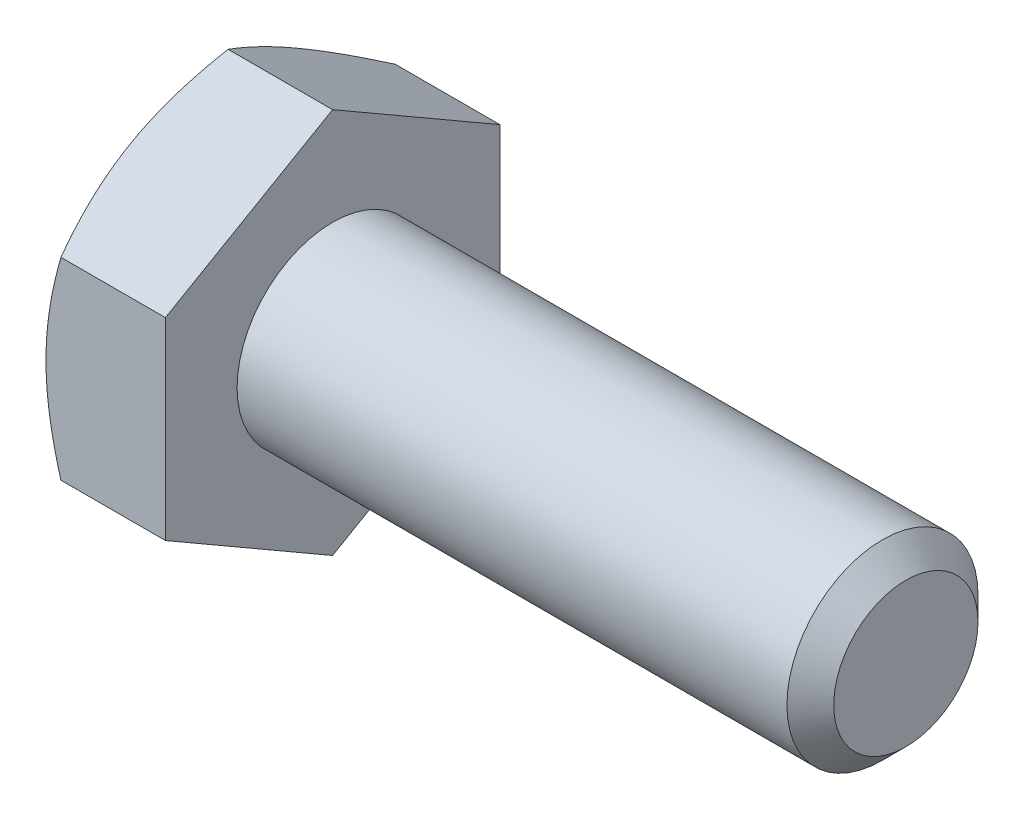
from build123d import *

# Parameters (mm, degrees)
SKETCH5_R           = 3.175
BOSS_EXTRUDE3_DEPTH = 19.05
CHAMFER1_SIZE       = 0.77724
BOSS_EXTRUDE4_DEPTH = 3.96875
SKETCH8_OUTSIDE_W   = 102.036
SKETCH8_OUTSIDE_H   = 103.756
SKETCH8_OUTSIDE_R   = 5.55625
CUT_EXTRUDE3_DEPTH  = 24.01875
CUT_EXTRUDE3_TAPER  = 60
CUT_EXTRUDE4_DEPTH  = 0.254
CIRPATTERN1_COUNT   = 3


with BuildPart() as part:
    # Sketch5 → Boss-Extrude3 (new body)
    with BuildSketch(Plane(origin=(11.509375, 0, 0), x_dir=(0, 0, -1), z_dir=(1, 0, 0))):
        Circle(SKETCH5_R)
    extrude(amount=-BOSS_EXTRUDE3_DEPTH)

    # Chamfer1
    chamfer1_edges = [part.edges().sort_by_distance(p)[0] for p in [
        (11.509375, 0, 3.175),
    ]]
    chamfer(chamfer1_edges, length=CHAMFER1_SIZE)

    # Sketch6 → Boss-Extrude4 (add)
    with BuildSketch(Plane.ZY.offset(7.540625)):
        Polygon((5.55625, 3.207902433), (0, 6.415804866), (-5.55625, 3.207902433), (-5.55625, -3.207902433), (0, -6.415804866), (5.55625, -3.207902433), align=None)
    extrude(amount=BOSS_EXTRUDE4_DEPTH)

    # Sketch8 outside → Cut-Extrude3 (cut, through all)
    with BuildSketch(Plane.ZY.offset(11.509375)):
        Rectangle(SKETCH8_OUTSIDE_W, SKETCH8_OUTSIDE_H)
        Circle(SKETCH8_OUTSIDE_R, mode=Mode.SUBTRACT)
    extrude(amount=-CUT_EXTRUDE3_DEPTH, taper=CUT_EXTRUDE3_TAPER, mode=Mode.SUBTRACT)

    # Sketch12 → Cut-Extrude4 (cut)
    with BuildSketch(Plane.ZY.offset(11.509375)):
        with BuildLine():
            Line((0.1666875, 4.2783125), (0.1666875, 2.3891875))
            ThreePointArc((0.1666875, 2.3891875), (0, 2.2225), (-0.1666875, 2.3891875))
            Line((-0.1666875, 2.3891875), (-0.1666875, 4.2783125))
            ThreePointArc((-0.1666875, 4.2783125), (0, 4.445), (0.1666875, 4.2783125))
        make_face()
    cut_extrude4 = extrude(amount=-CUT_EXTRUDE4_DEPTH, mode=Mode.SUBTRACT)

    # CirPattern1: Cut-Extrude4 ×3 about axis
    cirpattern1_axis = Axis((0, 0, 0), (1, 0, 0))
    for i in range(1, CIRPATTERN1_COUNT):
        add(cut_extrude4.rotate(cirpattern1_axis, i * 360 / CIRPATTERN1_COUNT), mode=Mode.SUBTRACT)


solid = part.part
